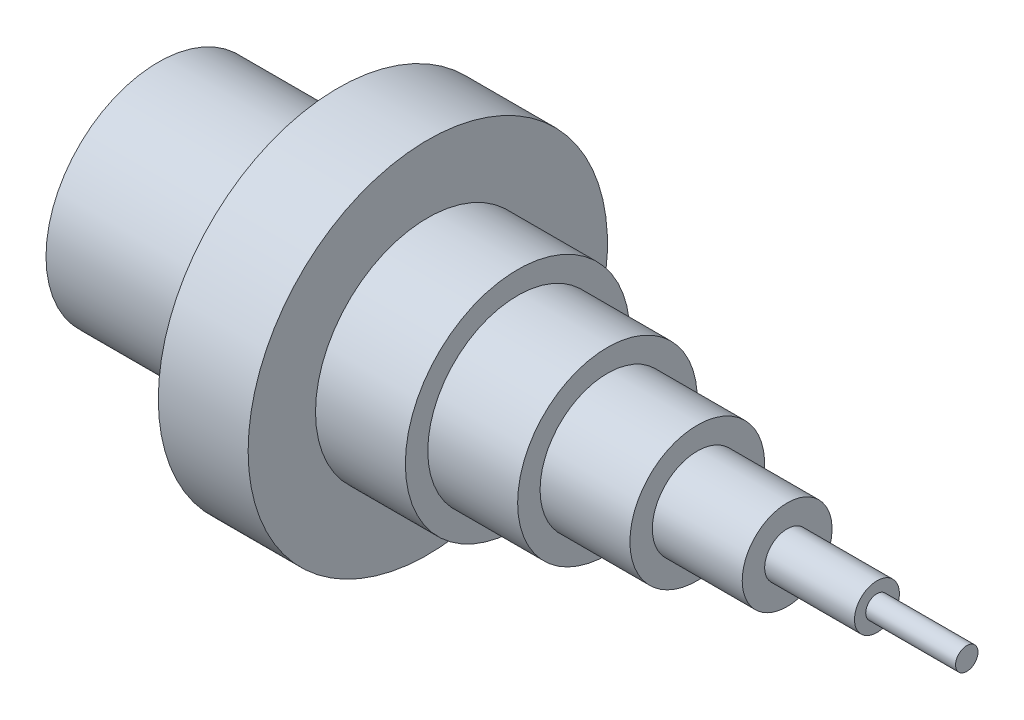
from build123d import *

# Parameters (mm, degrees)
SKETCH2_R          = 20
CUT_EXTRUDE1_DEPTH = 40


with BuildPart() as part:
    # Sketch1 → Revolve1 (revolve)
    with BuildSketch(Plane.XY, mode=Mode.PRIVATE) as revolve1_sk:
        Polygon((0, 0), (0, 25), (40, 25), (40, 40), (60, 40), (60, 25), (80, 25), (80, 20), (100, 20), (100, 15), (120, 15), (120, 10), (140, 10), (140, 5), (160, 5), (160, 2.5), (180, 2.5), (180, 0), align=None)
    revolve(revolve1_sk.sketch.rotate(Axis((-116.666666667, 0, 0), (1, 0, 0)), 90), axis=Axis((-116.666666667, 0, 0), (1, 0, 0)))  # turned: the seam where the file's is

    # Sketch2 → Cut-Extrude1 (cut)
    with BuildSketch(Plane.ZY):
        Circle(SKETCH2_R)
    extrude(amount=-CUT_EXTRUDE1_DEPTH, mode=Mode.SUBTRACT)


solid = part.part
